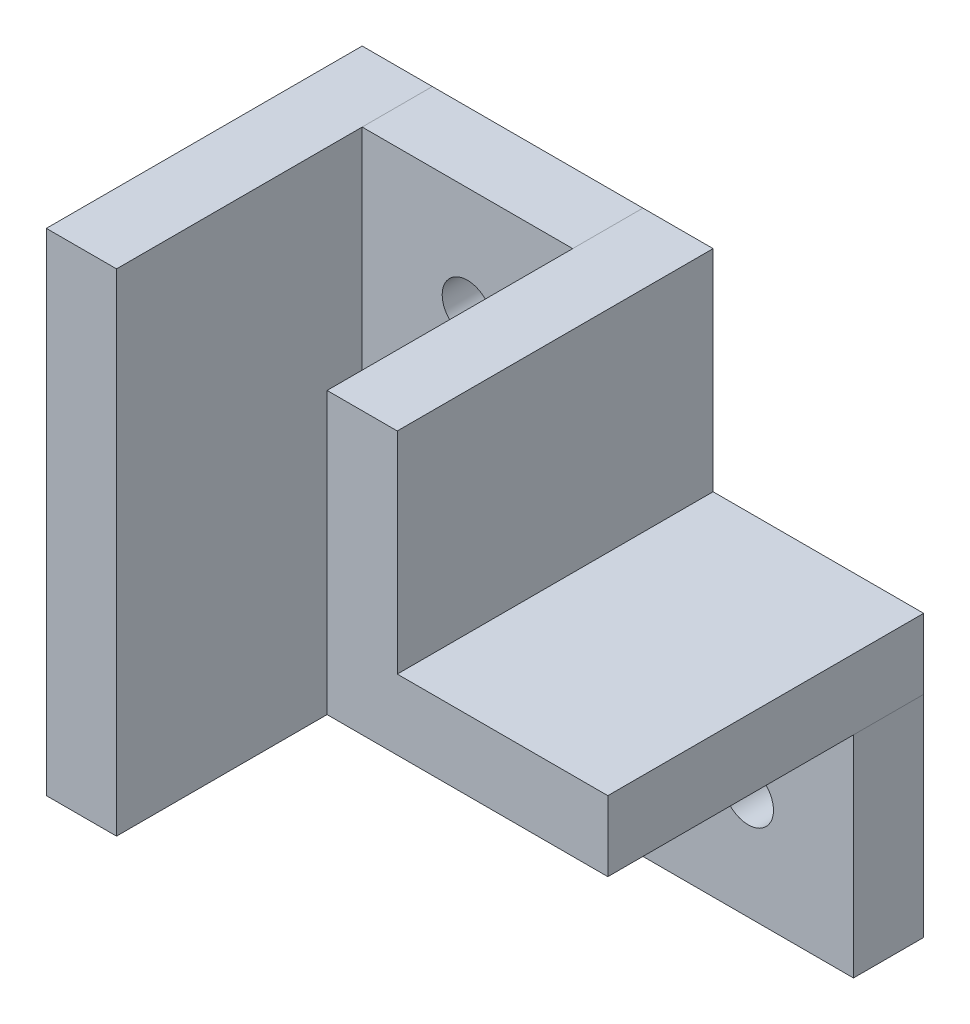
from build123d import *

# Parameters (mm, degrees)
BOSS_EXTRUDE1_DEPTH = 5
BOSS_EXTRUDE2_DEPTH = 22.5
SKETCH3_W           = 5
SKETCH3_H           = 35
BOSS_EXTRUDE3_DEPTH = 22.5
SKETCH4_R           = 1.8
CUT_EXTRUDE1_DEPTH  = 23.5


with BuildPart() as part:
    # Sketch1 → Boss-Extrude1 (new body)
    with BuildSketch(Plane.XY):
        Polygon((-7.529880478, -25.806772908), (27.470119522, -25.806772908), (27.470119522, -10.806772908), (7.470119522, -10.806772908), (7.470119522, 9.193227092), (-7.529880478, 9.193227092), align=None)
    extrude(amount=BOSS_EXTRUDE1_DEPTH)

    # Sketch4 → Cut-Extrude1 (cut, through all)
    with BuildSketch(Plane(origin=(0, 0, 0), x_dir=(-1, 0, 0), z_dir=(0, 0, -1))):
        with Locations((0.029880478, 1.693227092)):
            Circle(SKETCH4_R)
        with Locations((-19.970119522, -18.306772908)):
            Circle(SKETCH4_R)
    extrude(amount=-CUT_EXTRUDE1_DEPTH, mode=Mode.SUBTRACT)


with BuildPart() as body_2:
    # Sketch2 → Boss-Extrude2 (new body)
    with BuildSketch(Plane(origin=(0, 0, 0), x_dir=(-1, 0, 0), z_dir=(0, 0, -1))):
        Polygon((-7.470119522, 9.193227092), (-12.470119522, 9.193227092), (-12.470119522, -5.806772908), (-27.470119522, -5.806772908), (-27.470119522, -10.806772908), (-7.470119522, -10.806772908), align=None)
    extrude(amount=-BOSS_EXTRUDE2_DEPTH)


with BuildPart() as body_3:
    # Sketch3 → Boss-Extrude3 (new body)
    with BuildSketch(Plane(origin=(0, 0, 0), x_dir=(-1, 0, 0), z_dir=(0, 0, -1))):
        with Locations((10.029880478, -8.306772908)):
            Rectangle(SKETCH3_W, SKETCH3_H)
    extrude(amount=-BOSS_EXTRUDE3_DEPTH)


solid = Compound([part.part, body_2.part, body_3.part])
